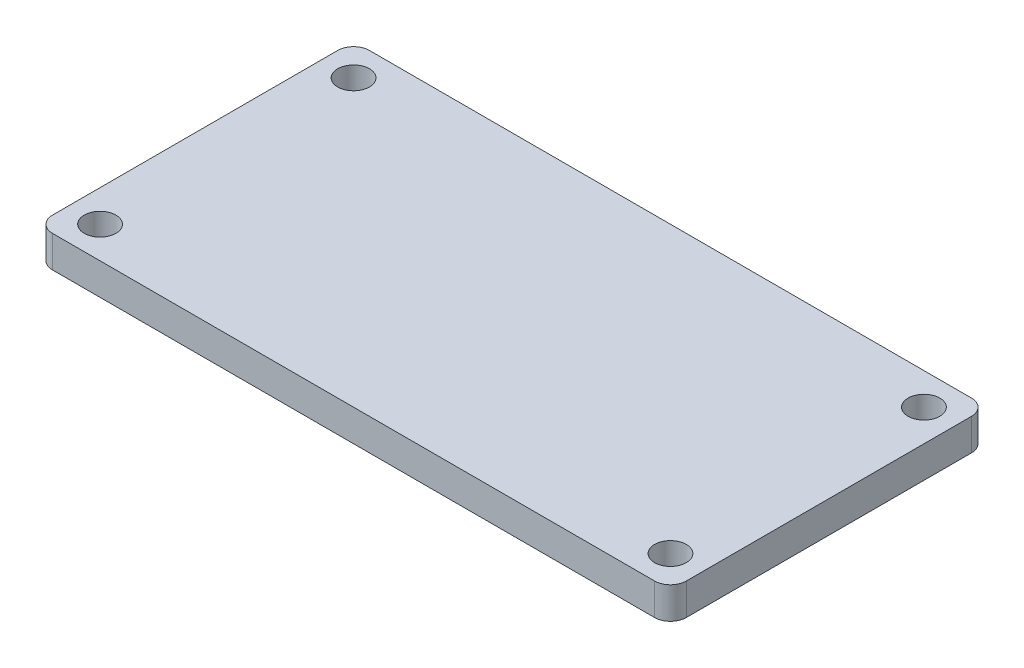
from build123d import *

# Parameters (mm, degrees)
BOSS_EXTRUDE1_DEPTH = 10
SKETCH2_R           = 5
CUT_EXTRUDE1_DEPTH  = 11


with BuildPart() as part:
    # Sketch1 → Boss-Extrude1 (new body)
    with BuildSketch(Plane(origin=(0, 0, 0), x_dir=(1, 0, 0), z_dir=(0, 1, 0))):
        with BuildLine():
            Line((90.892146618, 138.969332263), (90.892146618, 48.969332263))
            ThreePointArc((90.892146618, 48.969332263), (92.356612712, 45.433798357), (95.892146618, 43.969332263))
            Line((95.892146618, 43.969332263), (285.892146618, 43.969332263))
            ThreePointArc((285.892146618, 43.969332263), (289.427680524, 45.433798357), (290.892146618, 48.969332263))
            Line((290.892146618, 48.969332263), (290.892146618, 138.969332263))
            ThreePointArc((290.892146618, 138.969332263), (289.427680524, 142.504866169), (285.892146618, 143.969332263))
            Line((285.892146618, 143.969332263), (95.892146618, 143.969332263))
            ThreePointArc((95.892146618, 143.969332263), (92.356612712, 142.504866169), (90.892146618, 138.969332263))
        make_face()
    extrude(amount=BOSS_EXTRUDE1_DEPTH)

    # Sketch2 → Cut-Extrude1 (cut, through all)
    with BuildSketch(Plane(origin=(0, 10, 0), x_dir=(1, 0, 0), z_dir=(0, 1, 0))):
        with Locations((100.892146618, 53.969332263)):
            Circle(SKETCH2_R)
        with Locations((100.892146618, 133.969332263)):
            Circle(SKETCH2_R)
        with Locations((280.892146618, 133.969332263)):
            Circle(SKETCH2_R)
        with Locations((280.892146618, 53.969332263)):
            Circle(SKETCH2_R)
    extrude(amount=-CUT_EXTRUDE1_DEPTH, mode=Mode.SUBTRACT)


solid = part.part
